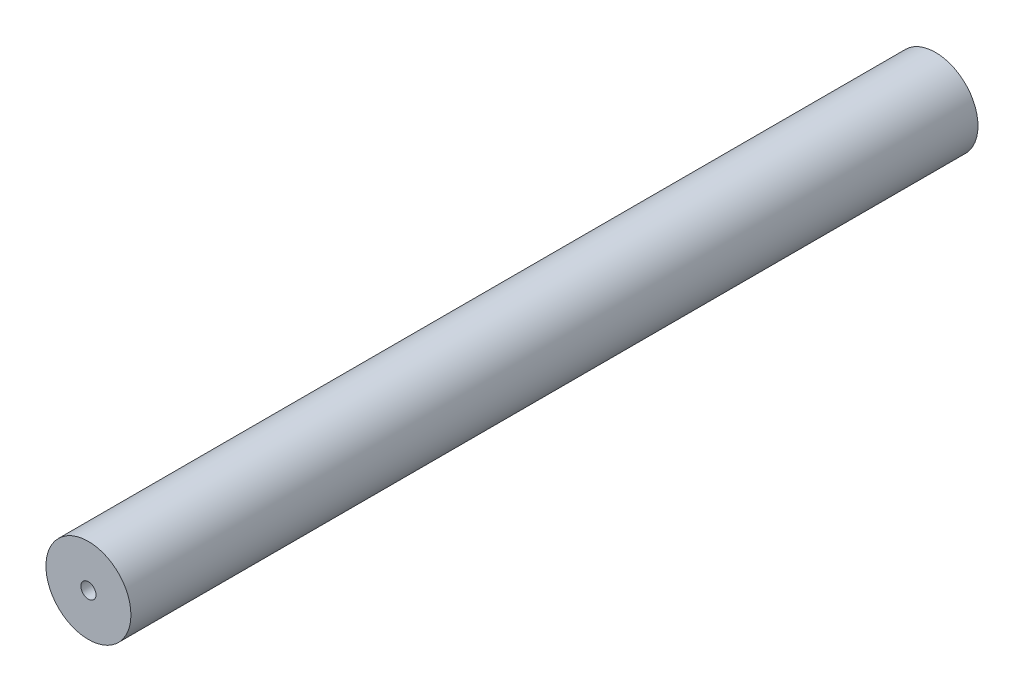
from build123d import *

# Parameters (mm, degrees)
SKETCH1_R           = 2.25
SKETCH1_R_2         = 0.4
BOSS_EXTRUDE1_DEPTH = 44.85


with BuildPart() as part:
    # Sketch1 → Boss-Extrude1 (new body)
    with BuildSketch(Plane.XY):
        Circle(SKETCH1_R)
        Circle(SKETCH1_R_2, mode=Mode.SUBTRACT)
    extrude(amount=BOSS_EXTRUDE1_DEPTH)


solid = part.part
